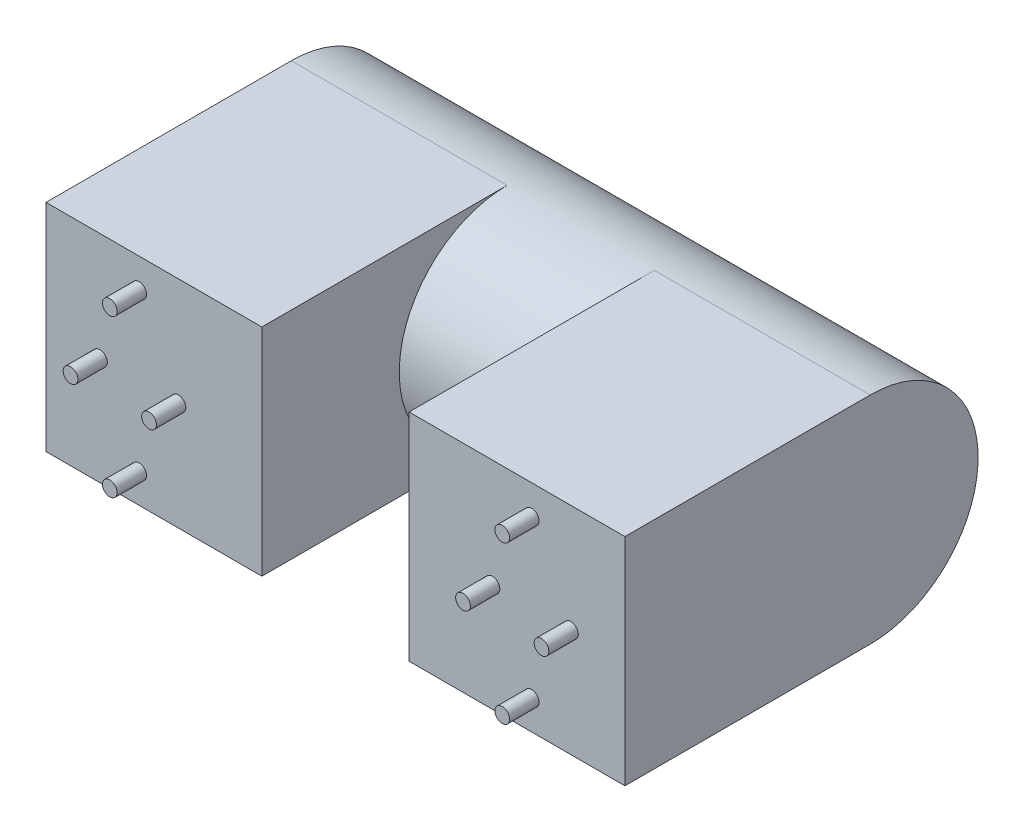
from build123d import *

# Parameters (mm, degrees)
ESBO_O1_W                  = 22
ESBO_O1_H                  = 22
RESSALTO_EXTRUS_O1_DEPTH   = 24.25
RESSALTO_EXTRUS_O1_2_DEPTH = 24.25
ESBO_O2_R                  = 11
RESSALTO_EXTRUS_O2_DEPTH   = 15
CORTE_EXTRUS_O1_DEPTH      = 65.730692102
CORTE_EXTRUS_O1_DEPTH_BACK = 65.730692102
ESBO_O4_R                  = 0.75
RESSALTO_EXTRUS_O3_DEPTH   = 3


with BuildPart() as part:
    # Esboço1 → Ressalto-extrusão1 (new, symmetric)
    with BuildSketch(Plane.XY):
        Rectangle(ESBO_O1_W, ESBO_O1_H)
    extrude(amount=RESSALTO_EXTRUS_O1_DEPTH, both=True)



with BuildPart() as body_2:
    # Esboço1 → Ressalto-extrus_o1 2 (new, symmetric)
    with BuildSketch(Plane.XY):
        with Locations((37, 0)):
            Rectangle(ESBO_O1_W, ESBO_O1_H)
    extrude(amount=RESSALTO_EXTRUS_O1_2_DEPTH, both=True)


with BuildPart() as part_1:
    add(part.part)

    add(body_2.part)  # Ressalto-extrusão2 merges body 2
    # Esboço2 → Ressalto-extrusão2 (add)
    with BuildSketch(Plane(origin=(11, 0, 0), x_dir=(0, 0, -1), z_dir=(1, 0, 0))):
        with Locations(Location((0.75, 0, 0), (0, 0, 270))):
            Circle(ESBO_O2_R)
    extrude(amount=RESSALTO_EXTRUS_O2_DEPTH)

    # Esboço3 → Corte-extrusão1 (cut, two sides)
    with BuildSketch(Plane(origin=(48, 0, 0), x_dir=(0, 0, -1), z_dir=(1, 0, 0))) as corte_extrus_o1_sk:
        with BuildLine():
            Line((0.75, 11), (24.25, 11))
            Line((24.25, 11), (24.25, -11))
            Line((24.25, -11), (0.75, -11))
            ThreePointArc((0.75, -11), (11.75, 0), (0.75, 11))
        make_face()
    extrude(amount=CORTE_EXTRUS_O1_DEPTH, mode=Mode.SUBTRACT)
    extrude(corte_extrus_o1_sk.sketch, amount=-CORTE_EXTRUS_O1_DEPTH_BACK, mode=Mode.SUBTRACT)

    # Esboço4 → Ressalto-extrusão3 (add)
    with BuildSketch(Plane.XY.offset(24.25)):
        with Locations((-5.5, 0)):
            Circle(ESBO_O4_R)
        with Locations((2.5, 0)):
            Circle(ESBO_O4_R)
        with Locations((-1.5, 8)):
            Circle(ESBO_O4_R)
        with Locations((-1.5, -8)):
            Circle(ESBO_O4_R)
        with Locations((34.5, 0)):
            Circle(ESBO_O4_R)
        with Locations((42.5, 0)):
            Circle(ESBO_O4_R)
        with Locations((38.5, -8)):
            Circle(ESBO_O4_R)
        with Locations((38.5, 8)):
            Circle(ESBO_O4_R)
    extrude(amount=RESSALTO_EXTRUS_O3_DEPTH)


solid = part_1.part
